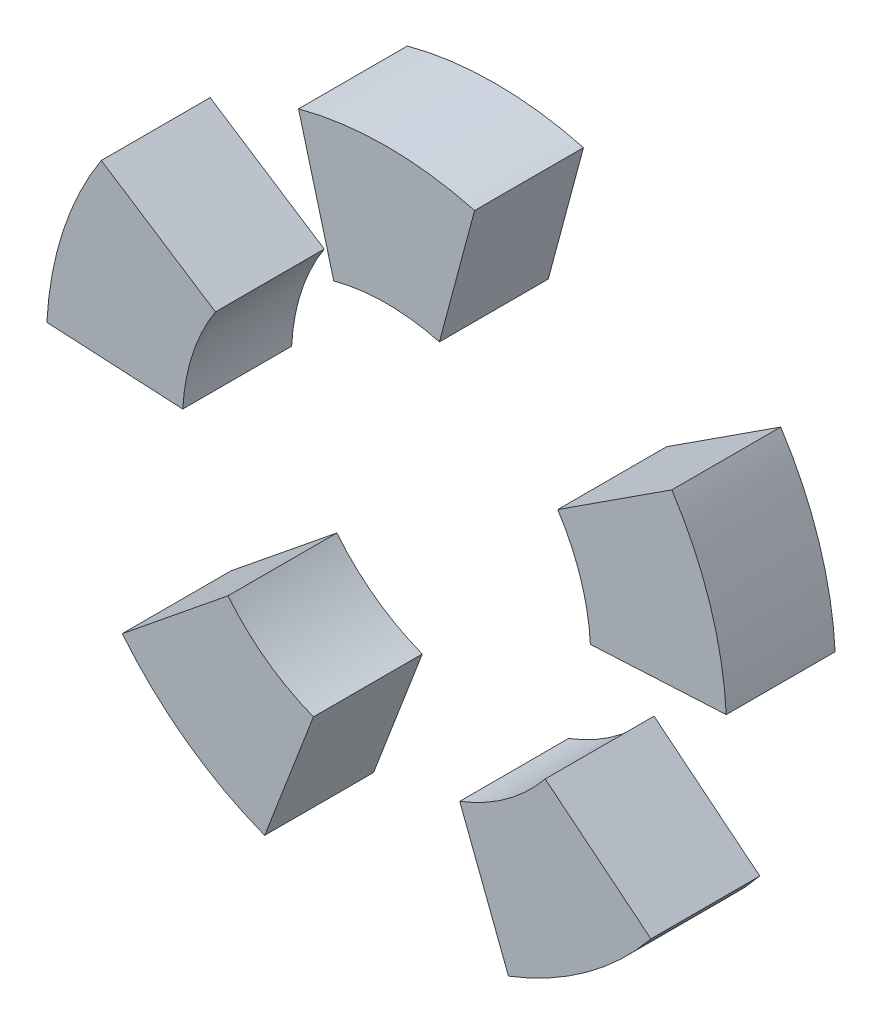
from build123d import *

# Parameters (mm, degrees)
BOSS_EXTRUDE1_DEPTH   = 8
BOSS_EXTRUDE1_2_DEPTH = 8
BOSS_EXTRUDE1_3_DEPTH = 8
BOSS_EXTRUDE1_4_DEPTH = 8
BOSS_EXTRUDE1_5_DEPTH = 8


with BuildPart() as part:
    # Sketch1 → Boss-Extrude1 (new body)
    with BuildSketch(Plane.XY):
        with BuildLine():
            Line((-3.882285677, 14.488887394), (-6.470476128, 24.148145657))
            ThreePointArc((-6.470476128, 24.148145657), (0, 25), (6.470476128, 24.148145657))
            Line((6.470476128, 24.148145657), (3.882285677, 14.488887394))
            ThreePointArc((3.882285677, 14.488887394), (0, 15), (-3.882285677, 14.488887394))
        make_face()
    extrude(amount=BOSS_EXTRUDE1_DEPTH)


with BuildPart() as body_2:
    # Sketch1 → Boss-Extrude1 2 (new body)
    with BuildSketch(Plane.XY):
        with BuildLine():
            Line((12.580058519, 8.169585525), (20.966764199, 13.615975875))
            ThreePointArc((20.966764199, 13.615975875), (23.776412907, 7.725424859), (24.965738369, 1.308398906))
            Line((24.965738369, 1.308398906), (14.979443021, 0.785039344))
            ThreePointArc((14.979443021, 0.785039344), (14.265847744, 4.635254916), (12.580058519, 8.169585525))
        make_face()
    extrude(amount=BOSS_EXTRUDE1_2_DEPTH)


with BuildPart() as body_3:
    # Sketch1 → Boss-Extrude1 3 (new body)
    with BuildSketch(Plane.XY):
        with BuildLine():
            Line((11.657189422, -9.439805866), (19.428649036, -15.733009776))
            ThreePointArc((19.428649036, -15.733009776), (14.694631307, -20.225424859), (8.959198739, -23.339510662))
            Line((8.959198739, -23.339510662), (5.375519243, -14.003706397))
            ThreePointArc((5.375519243, -14.003706397), (8.816778784, -12.135254916), (11.657189422, -9.439805866))
        make_face()
    extrude(amount=BOSS_EXTRUDE1_3_DEPTH)


with BuildPart() as body_4:
    # Sketch1 → Boss-Extrude1 4 (new body)
    with BuildSketch(Plane.XY):
        with BuildLine():
            Line((-5.375519243, -14.003706397), (-8.959198739, -23.339510662))
            ThreePointArc((-8.959198739, -23.339510662), (-14.694631307, -20.225424859), (-19.428649036, -15.733009776))
            Line((-19.428649036, -15.733009776), (-11.657189422, -9.439805866))
            ThreePointArc((-11.657189422, -9.439805866), (-8.816778784, -12.135254916), (-5.375519243, -14.003706397))
        make_face()
    extrude(amount=BOSS_EXTRUDE1_4_DEPTH)


with BuildPart() as body_5:
    # Sketch1 → Boss-Extrude1 5 (new body)
    with BuildSketch(Plane.XY):
        with BuildLine():
            Line((-14.979443021, 0.785039344), (-24.965738369, 1.308398906))
            ThreePointArc((-24.965738369, 1.308398906), (-23.776412907, 7.725424859), (-20.966764199, 13.615975875))
            Line((-20.966764199, 13.615975875), (-12.580058519, 8.169585525))
            ThreePointArc((-12.580058519, 8.169585525), (-14.265847744, 4.635254916), (-14.979443021, 0.785039344))
        make_face()
    extrude(amount=BOSS_EXTRUDE1_5_DEPTH)


solid = Compound([part.part, body_2.part, body_3.part, body_4.part, body_5.part])
